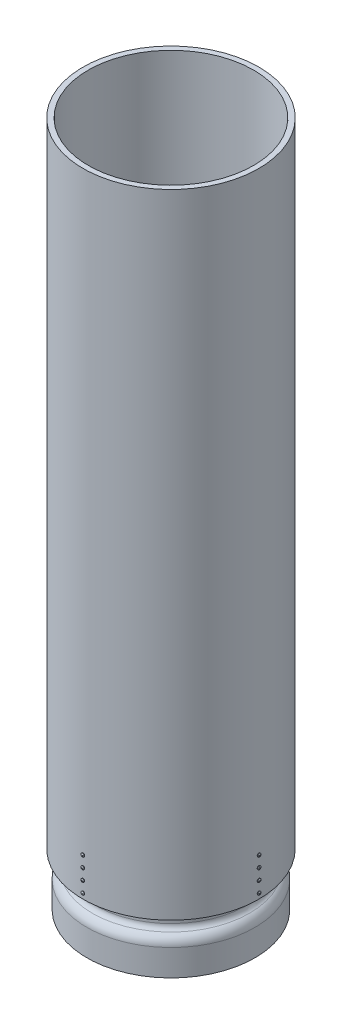
from build123d import *

# Parameters (mm, degrees)
SKETCH2_W           = 15.0622
SKETCH2_H           = 1828.8
BOSS_EXTRUDE1_DEPTH = 127
SKETCH4_R           = 2.5527
CUT_EXTRUDE1_DEPTH  = 25.4
CIRPATTERN1_COUNT   = 4
CIRPATTERN2_COUNT   = 4
CUT_EXTRUDE2_DEPTH  = 1.5875
LPATTERN1_COUNT     = 4
LPATTERN1_PITCH     = 31.75
CIRPATTERN3_COUNT   = 4


with BuildPart() as part:
    # Sketch2 → Revolve1 (revolve)
    with BuildSketch(Plane.XY, mode=Mode.PRIVATE) as revolve1_sk:
        with BuildLine():
            Line((-228.6, 0), (-228.6, 76.2))
            ThreePointArc((-228.6, 76.2), (-226.263720515, 84.925615117), (-219.880016129, 91.316458513))
            ThreePointArc((-219.880016129, 91.316458513), (-208.273280881, 102.936173779), (-204.0255, 118.800928537))
            Line((-204.0255, 118.800928537), (-204.0255, 279.4))
            Line((-204.0255, 279.4), (-218.3003, 279.4))
            Line((-218.3003, 279.4), (-218.3003, 118.800928537))
            ThreePointArc((-218.3003, 118.800928537), (-220.636579485, 110.07531342), (-227.020283871, 103.684470024))
            ThreePointArc((-227.020283871, 103.684470024), (-238.627019119, 92.064754759), (-242.8748, 76.2))
            Line((-242.8748, 76.2), (-242.8748, 0))
            Line((-242.8748, 0), (-228.6, 0))
        make_face()
        with Locations((-246.4689, 1066.8)):
            Rectangle(SKETCH2_W, SKETCH2_H)
    revolve(revolve1_sk.sketch.rotate(Axis((0, -96.465125913, 0), (0, 1, 0)), 270), axis=Axis((0, -96.465125913, 0), (0, 1, 0)))


with BuildPart() as body_2:
    # Sketch3 → Boss-Extrude1 (new body)
    with BuildSketch(Plane.XZ.offset(-152.4)):
        with BuildLine():
            Line((-9.525, 238.747872543), (-9.525, 218.092400957))
            ThreePointArc((-9.525, 218.092400957), (0, 218.3003), (9.525, 218.092400957))
            Line((9.525, 218.092400957), (9.525, 238.747872543))
            ThreePointArc((9.525, 238.747872543), (0, 238.9378), (-9.525, 238.747872543))
        make_face()
    extrude(amount=-BOSS_EXTRUDE1_DEPTH)


with BuildPart() as cut_extrude1_tool:
    # Sketch4 → Cut-Extrude1 (new body)
    with BuildSketch(Plane.XY.offset(254)):
        with Locations((0, 168.275)):
            Circle(SKETCH4_R)
        with Locations((0, 200.025)):
            Circle(SKETCH4_R)
        with Locations((0, 231.775)):
            Circle(SKETCH4_R)
        with Locations((0, 263.525)):
            Circle(SKETCH4_R)
    cut_extrude1 = extrude(amount=-CUT_EXTRUDE1_DEPTH)


with BuildPart() as part_1:
    add(part.part)

    # Cut-Extrude1: cut by cut_extrude1_tool
    add(cut_extrude1_tool.part, mode=Mode.SUBTRACT)

    # CirPattern2: Cut-Extrude1 ×4 about axis
    cirpattern2_axis = Axis((0, 152.4, 0), (0, -1, 0))
    for i in range(1, CIRPATTERN2_COUNT):
        add(cut_extrude1.rotate(cirpattern2_axis, i * 360 / CIRPATTERN2_COUNT), mode=Mode.SUBTRACT)


with BuildPart() as body_2_1:
    add(body_2.part)

    # Cut-Extrude1: cut by cut_extrude1_tool
    add(cut_extrude1_tool.part, mode=Mode.SUBTRACT)


with BuildPart() as cirpattern1_1:
    # CirPattern1: pattern copy
    add(body_2_1.part.rotate(Axis((0, 0, 0), (0, 1, 0)), 1 * 360 / CIRPATTERN1_COUNT))


with BuildPart() as cirpattern1_2:
    # CirPattern1: pattern copy
    add(body_2_1.part.rotate(Axis((0, 0, 0), (0, 1, 0)), 2 * 360 / CIRPATTERN1_COUNT))


with BuildPart() as cirpattern1_3:
    # CirPattern1: pattern copy
    add(body_2_1.part.rotate(Axis((0, 0, 0), (0, 1, 0)), 3 * 360 / CIRPATTERN1_COUNT))


with BuildPart() as body_6:
    # Sketch6 → Revolve2 (revolve)
    with BuildSketch(Plane(origin=(0, 0, 0), x_dir=(0, 0, -1), z_dir=(1, 0, 0)), mode=Mode.PRIVATE) as revolve2_sk:
        with BuildLine():
            Line((-254, 263.525), (-254, 258.7879))
            Line((-254, 258.7879), (-255.5875, 258.7879))
            ThreePointArc((-255.5875, 258.7879), (-256.915582066, 260.992870318), (-257.3782, 263.525))
            Line((-257.3782, 263.525), (-254, 263.525))
        make_face()
    revolve(revolve2_sk.sketch.rotate(Axis((0, 263.525, 277.644724076), (0, 0, -1)), 180), axis=Axis((0, 263.525, 277.644724076), (0, 0, -1)))

    # Sketch7 → Cut-Extrude2 (cut)
    with BuildSketch(Plane.XY.offset(257.3782)):
        Polygon((2.38125, 263.921875), (0.396875, 263.921875), (0.396875, 265.90625), (-0.396875, 265.90625), (-0.396875, 263.921875), (-2.38125, 263.921875), (-2.38125, 263.128125), (-0.396875, 263.128125), (-0.396875, 261.14375), (0.396875, 261.14375), (0.396875, 263.128125), (2.38125, 263.128125), align=None)
    extrude(amount=-CUT_EXTRUDE2_DEPTH, mode=Mode.SUBTRACT)


with BuildPart() as lpattern1_1:
    # LPattern1: pattern copy
    add(body_6.part.moved(Location(Vector(0, -1, 0) * (1 * LPATTERN1_PITCH))))


with BuildPart() as lpattern1_2:
    # LPattern1: pattern copy
    add(body_6.part.moved(Location(Vector(0, -1, 0) * (2 * LPATTERN1_PITCH))))


with BuildPart() as lpattern1_3:
    # LPattern1: pattern copy
    add(body_6.part.moved(Location(Vector(0, -1, 0) * (3 * LPATTERN1_PITCH))))


with BuildPart() as cirpattern3_1:
    # CirPattern3: pattern copy
    add(lpattern1_1.part.rotate(Axis((0, 0, 0), (0, 1, 0)), 1 * 360 / CIRPATTERN3_COUNT))


with BuildPart() as cirpattern3_2:
    # CirPattern3: pattern copy
    add(lpattern1_1.part.rotate(Axis((0, 0, 0), (0, 1, 0)), 2 * 360 / CIRPATTERN3_COUNT))


with BuildPart() as cirpattern3_3:
    # CirPattern3: pattern copy
    add(lpattern1_1.part.rotate(Axis((0, 0, 0), (0, 1, 0)), 3 * 360 / CIRPATTERN3_COUNT))


with BuildPart() as cirpattern3_4:
    # CirPattern3: pattern copy
    add(lpattern1_3.part.rotate(Axis((0, 0, 0), (0, 1, 0)), 1 * 360 / CIRPATTERN3_COUNT))


with BuildPart() as cirpattern3_5:
    # CirPattern3: pattern copy
    add(lpattern1_3.part.rotate(Axis((0, 0, 0), (0, 1, 0)), 2 * 360 / CIRPATTERN3_COUNT))


with BuildPart() as cirpattern3_6:
    # CirPattern3: pattern copy
    add(lpattern1_3.part.rotate(Axis((0, 0, 0), (0, 1, 0)), 3 * 360 / CIRPATTERN3_COUNT))


with BuildPart() as cirpattern3_7:
    # CirPattern3: pattern copy
    add(lpattern1_2.part.rotate(Axis((0, 0, 0), (0, 1, 0)), 1 * 360 / CIRPATTERN3_COUNT))


with BuildPart() as cirpattern3_8:
    # CirPattern3: pattern copy
    add(lpattern1_2.part.rotate(Axis((0, 0, 0), (0, 1, 0)), 2 * 360 / CIRPATTERN3_COUNT))


with BuildPart() as cirpattern3_9:
    # CirPattern3: pattern copy
    add(lpattern1_2.part.rotate(Axis((0, 0, 0), (0, 1, 0)), 3 * 360 / CIRPATTERN3_COUNT))


with BuildPart() as cirpattern3_10:
    # CirPattern3: pattern copy
    add(body_6.part.rotate(Axis((0, 0, 0), (0, 1, 0)), 1 * 360 / CIRPATTERN3_COUNT))


with BuildPart() as cirpattern3_11:
    # CirPattern3: pattern copy
    add(body_6.part.rotate(Axis((0, 0, 0), (0, 1, 0)), 2 * 360 / CIRPATTERN3_COUNT))


with BuildPart() as cirpattern3_12:
    # CirPattern3: pattern copy
    add(body_6.part.rotate(Axis((0, 0, 0), (0, 1, 0)), 3 * 360 / CIRPATTERN3_COUNT))


solid = Compound([part_1.part, body_2_1.part, cirpattern1_1.part, cirpattern1_2.part, cirpattern1_3.part, body_6.part, lpattern1_1.part, lpattern1_2.part, lpattern1_3.part, cirpattern3_1.part, cirpattern3_2.part, cirpattern3_3.part, cirpattern3_4.part, cirpattern3_5.part, cirpattern3_6.part, cirpattern3_7.part, cirpattern3_8.part, cirpattern3_9.part, cirpattern3_10.part, cirpattern3_11.part, cirpattern3_12.part])
